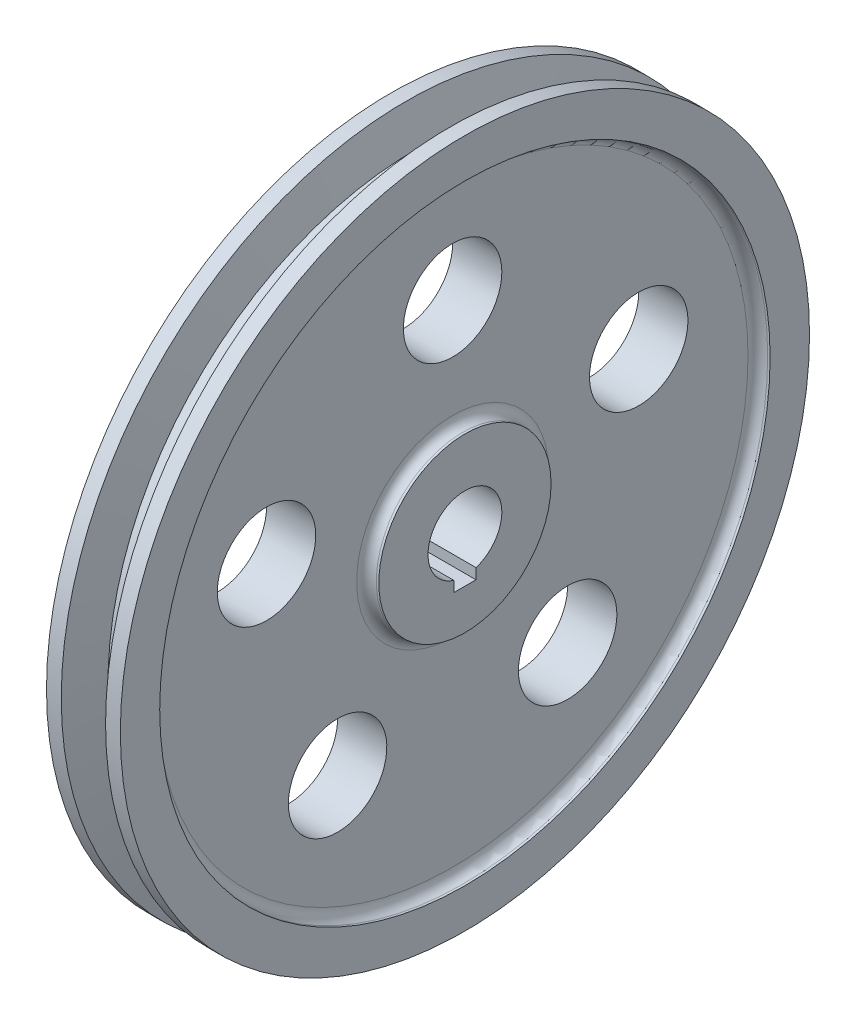
from build123d import *

# Parameters (mm, degrees)
SKETCH2_R         = 10
EXTRUDE1_DEPTH    = 10
CIRPATTERN1_COUNT = 5
SKETCH3_W         = 4.5
SKETCH3_H         = 2.3
EXTRUDE2_DEPTH    = 16


with BuildPart() as part:
    # Sketch1 → Revolve1 (revolve)
    with BuildSketch(Plane.XY):
        with BuildLine():
            Line((-7.5, 7.5), (7.5, 7.5))
            Line((7.5, 7.5), (7.5, 17.5))
            Line((7.5, 17.5), (7, 17.5))
            ThreePointArc((7, 17.5), (5.585786438, 18.085786438), (5, 19.5))
            Line((5, 19.5), (5, 60))
            ThreePointArc((5, 60), (5.585786438, 61.414213562), (7, 62))
            Line((7, 62), (7.5, 62))
            Line((7.5, 62), (7.5, 70))
            Line((7.5, 70), (4.5, 70))
            Line((4.5, 70), (2.5, 62.5))
            Line((2.5, 62.5), (-2.5, 62.5))
            Line((-2.5, 62.5), (-4.5, 70))
            Line((-4.5, 70), (-7.5, 70))
            Line((-7.5, 70), (-7.5, 62))
            Line((-7.5, 62), (-7, 62))
            ThreePointArc((-7, 62), (-5.585786438, 61.414213562), (-5, 60))
            Line((-5, 60), (-5, 19.5))
            ThreePointArc((-5, 19.5), (-5.585786438, 18.085786438), (-7, 17.5))
            Line((-7, 17.5), (-7.5, 17.5))
            Line((-7.5, 17.5), (-7.5, 7.5))
        make_face()
    revolve(axis=Axis((25.864037296, 0, 0), (-1, 0, 0)))

    # Sketch2 → Extrude1 (cut)
    with BuildSketch(Plane(origin=(5, 0, 0), x_dir=(0, 0, -1), z_dir=(1, 0, 0))):
        with Locations((0, 39.75)):
            Circle(SKETCH2_R)
    extrude1 = extrude(amount=-EXTRUDE1_DEPTH, mode=Mode.SUBTRACT)

    # CirPattern1: Extrude1 ×5 about axis
    cirpattern1_axis = Axis((0, 0, 0), (1, 0, 0))
    for i in range(1, CIRPATTERN1_COUNT):
        add(extrude1.rotate(cirpattern1_axis, i * 360 / CIRPATTERN1_COUNT), mode=Mode.SUBTRACT)

    # Sketch3 → Extrude2 (cut, through all)
    with BuildSketch(Plane(origin=(7.5, 0, 0), x_dir=(0, 0, -1), z_dir=(1, 0, 0))):
        with Locations((0, -8.15)):
            Rectangle(SKETCH3_W, SKETCH3_H)
    extrude(amount=-EXTRUDE2_DEPTH, mode=Mode.SUBTRACT)


solid = part.part
